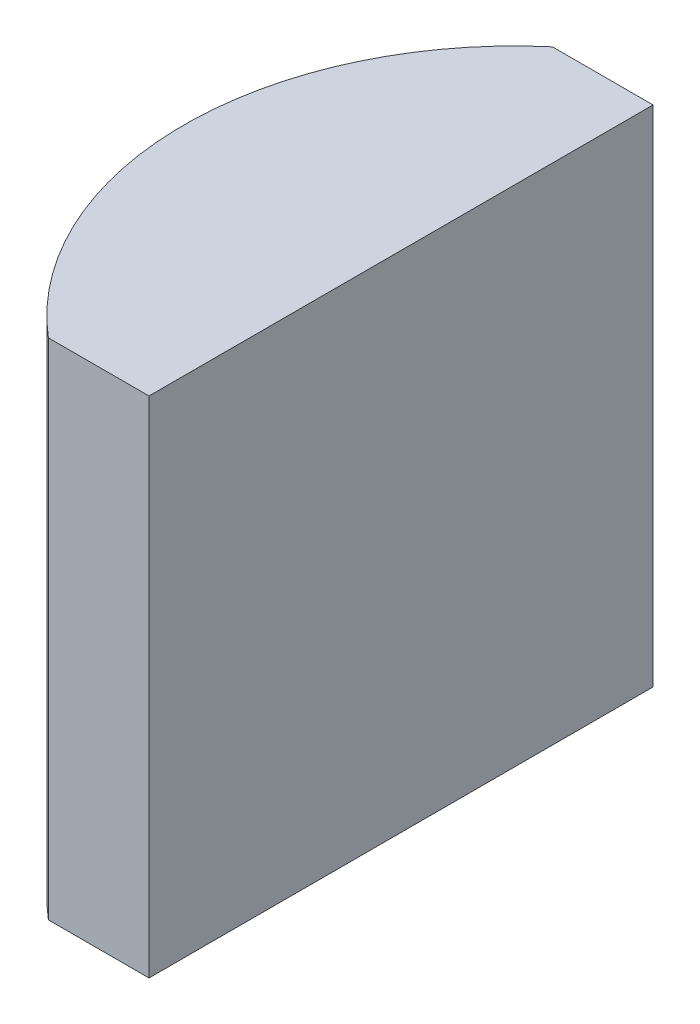
from build123d import *

# Parameters (mm, degrees)
EXTRUDE_1_DEPTH = 10


with BuildPart() as part:
    # 草图1 → 凸台-拉伸1 (new body)
    with BuildSketch(Plane(origin=(0, 0, 0), x_dir=(1, 0, 0), z_dir=(0, 1, 0))):
        with BuildLine():
            Line((0.108605696, 5), (2.105204335, 5))
            Line((2.105204335, 5), (2.105204335, -5))
            Line((2.105204335, -5), (0.108605696, -5))
            ThreePointArc((0.108605696, -5), (-2.204795665, 0), (0.108605696, 5))
        make_face()
    extrude(amount=EXTRUDE_1_DEPTH)


solid = part.part
